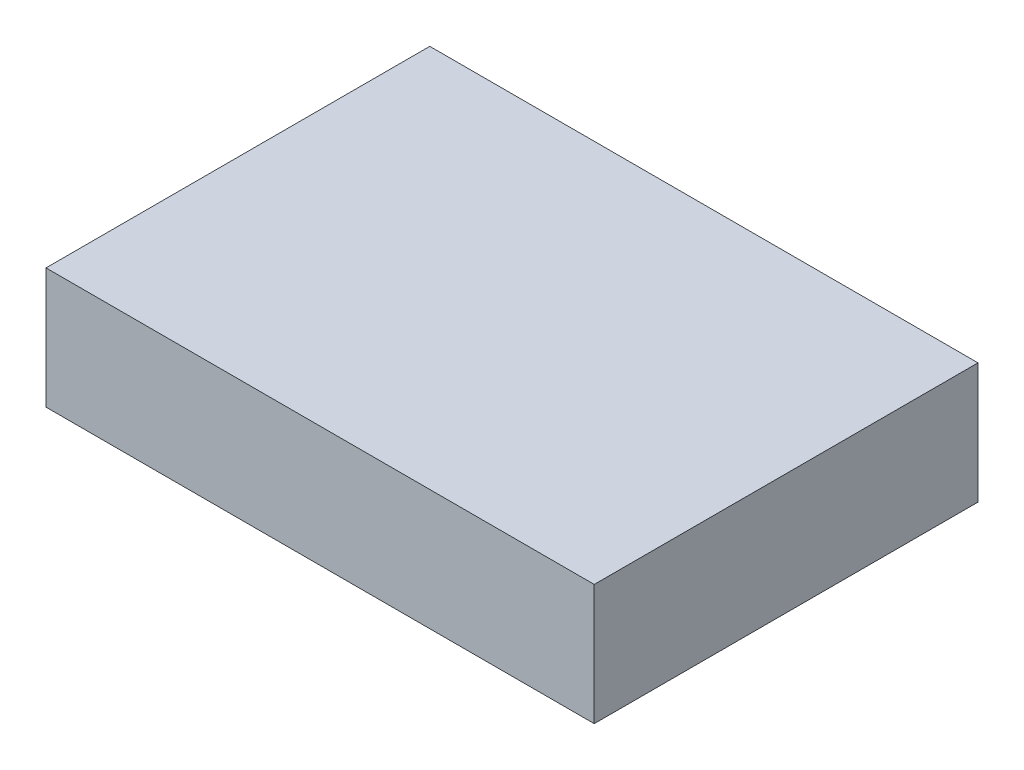
from build123d import *

# Parameters (mm, degrees)
SKETCH1_W           = 50
SKETCH1_H           = 35
BOSS_EXTRUDE1_DEPTH = 11


with BuildPart() as part:
    # Sketch1 → Boss-Extrude1 (new body)
    with BuildSketch(Plane(origin=(0, 0, 0), x_dir=(1, 0, 0), z_dir=(0, 1, 0))):
        with Locations((-9.25231787, -0.494877142)):
            Rectangle(SKETCH1_W, SKETCH1_H)
    extrude(amount=BOSS_EXTRUDE1_DEPTH)


solid = part.part
